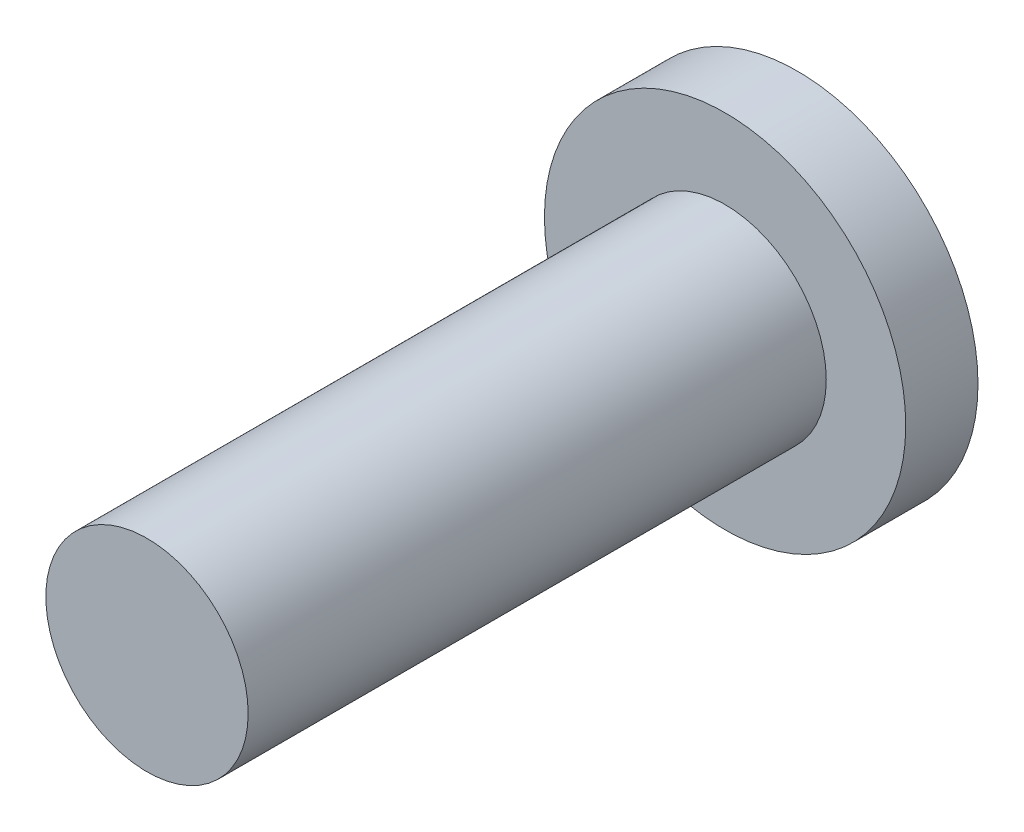
from build123d import *

# Parameters (mm, degrees)
SKETCH1_R           = 1.4
BOSS_EXTRUDE1_DEPTH = 8
SKETCH2_R           = 2.5
BOSS_EXTRUDE2_DEPTH = 1


with BuildPart() as part:
    # Sketch1 → Boss-Extrude1 (new body)
    with BuildSketch(Plane.XY):
        Circle(SKETCH1_R)
    extrude(amount=BOSS_EXTRUDE1_DEPTH)

    # Sketch2 → Boss-Extrude2 (add)
    with BuildSketch(Plane.XY):
        Circle(SKETCH2_R)
    extrude(amount=-BOSS_EXTRUDE2_DEPTH)


solid = part.part
